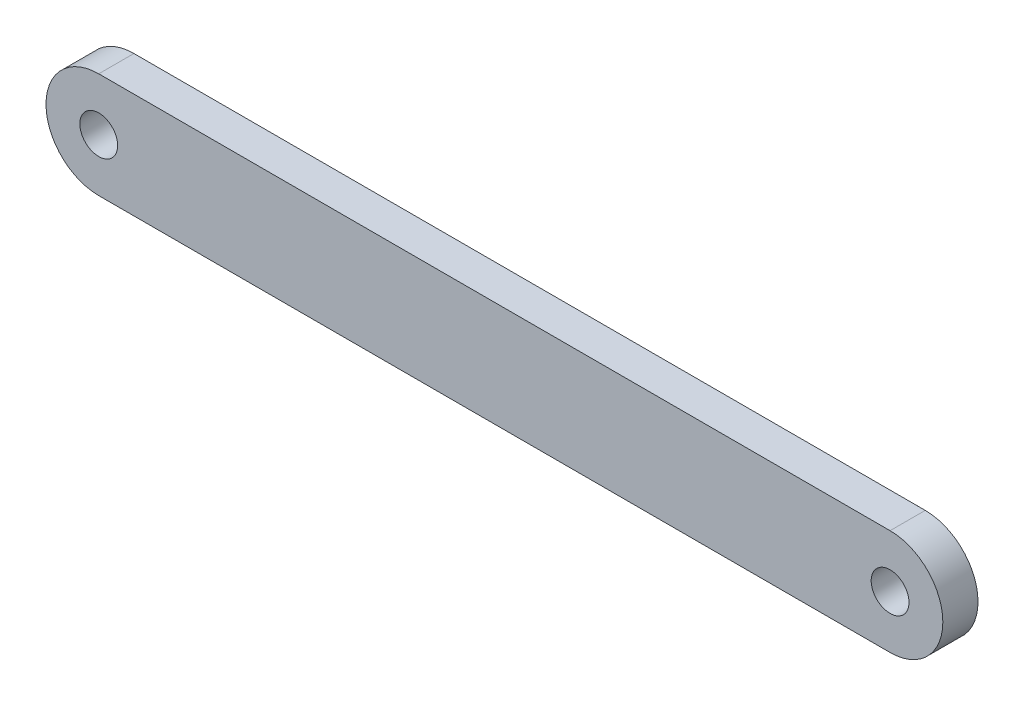
from build123d import *

# Parameters (mm, degrees)
SKETCH_1_R      = 2.15
EXTRUDE_1_DEPTH = 4


with BuildPart() as part:
    # 草图1 → 凸台-拉伸1 (new body)
    with BuildSketch(Plane.XY):
        with BuildLine():
            Line((0, 6), (90, 6))
            ThreePointArc((90, 6), (96, 0), (90, -6))
            Line((90, -6), (0, -6))
            ThreePointArc((0, -6), (-6, 0), (0, 6))
        make_face()
        Circle(SKETCH_1_R, mode=Mode.SUBTRACT)
        with Locations((90, 0)):
            Circle(SKETCH_1_R, mode=Mode.SUBTRACT)
    extrude(amount=EXTRUDE_1_DEPTH)


solid = part.part
